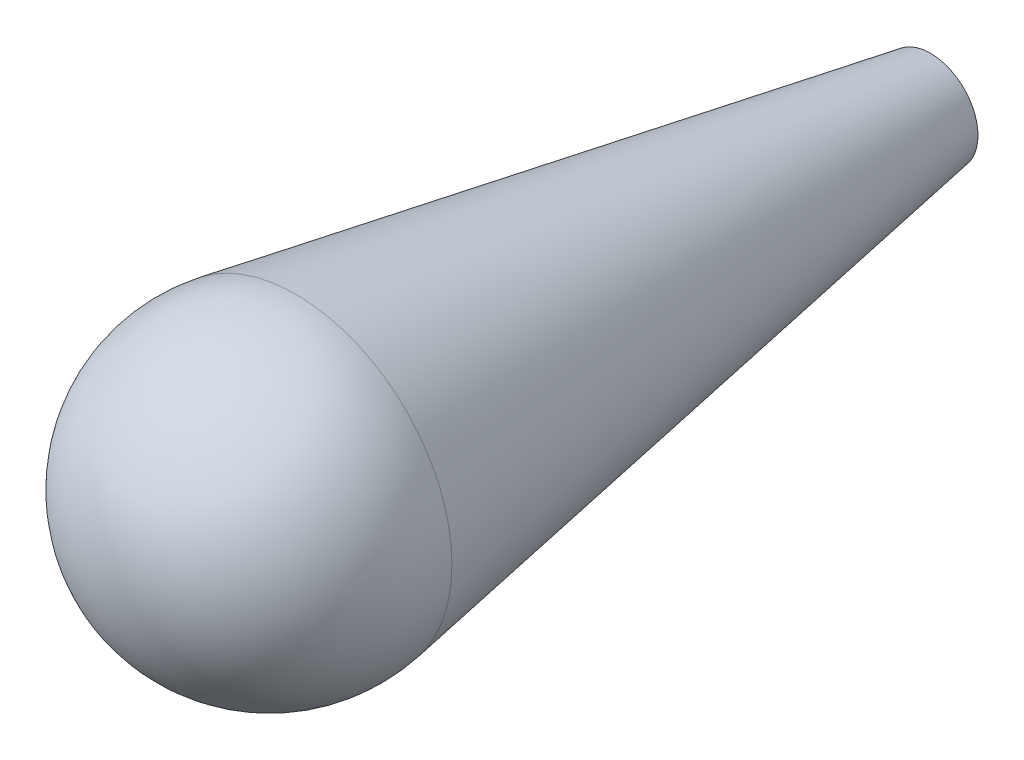
from build123d import *

# Parameters (mm, degrees)
SKETCH_2_R          = 3
CUT_EXTRUDE_1_DEPTH = 11
SKETCH_3_R          = 3
EXTRUDE_1_DEPTH     = 40
SKETCH_5_R          = 3
CUT_EXTRUDE_2_DEPTH = 40


with BuildPart() as part:
    # 草图1 → 旋转1 (revolve)
    with BuildSketch(Plane.XY):
        with BuildLine():
            Line((4.143240259, -9.101294422), (-4.143240259, 9.101294422))
            ThreePointArc((-4.143240259, 9.101294422), (-9.101294422, -4.143240259), (4.143240259, -9.101294422))
        make_face()
    revolve(axis=Axis((4.143240259, -9.101294422, 0), (-0.414324026, 0.910129442, 0)))

    # 草图2 → 切除-拉伸1 (cut, through all)
    with BuildSketch(Plane.XY):
        Circle(SKETCH_2_R)
    extrude(amount=-CUT_EXTRUDE_1_DEPTH, mode=Mode.SUBTRACT)

    # 草图3 → 凸台-拉伸1 (add)
    with BuildSketch(Plane(origin=(0, 0, 0), x_dir=(-1, 0, 0), z_dir=(0, 0, -1))):
        Circle(SKETCH_3_R)
    extrude(amount=EXTRUDE_1_DEPTH)

    # 草图4 → 旋转2 (revolve)
    with BuildSketch(Plane(origin=(0, 0, 0), x_dir=(1, 0, 0), z_dir=(0, 1, 0))):
        Polygon((-3, 0.512695407), (-9.857091429, 1.684561833), (-3, 41.808335168), align=None)
    revolve(axis=Axis((0, 0, 0), (0, 0, -1)))

    # 草图5 → 切除-拉伸2 (cut)
    with BuildSketch(Plane(origin=(0, 0, -40), x_dir=(-1, 0, 0), z_dir=(0, 0, -1))):
        Circle(SKETCH_5_R)
    extrude(amount=-CUT_EXTRUDE_2_DEPTH, mode=Mode.SUBTRACT)


solid = part.part
